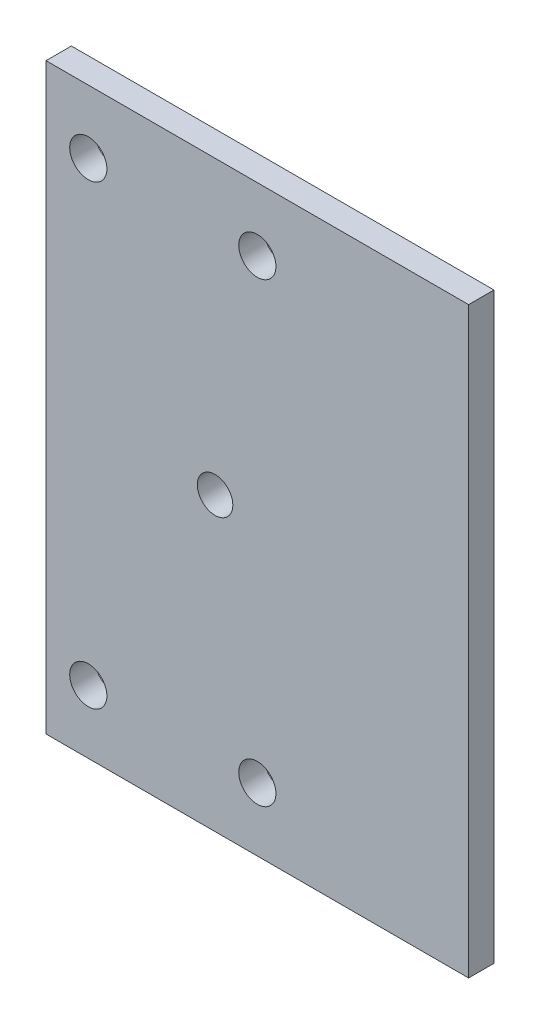
from build123d import *

# Parameters (mm, degrees)
SKETCH_1_W          = 40
SKETCH_1_H          = 29
EXTRUDE_1_DEPTH     = 3
SKETCH_3_W          = 40
SKETCH_3_H          = 3
EXTRUDE_2_DEPTH     = 3
SKETCH_4_W          = 40
SKETCH_4_H          = 3
EXTRUDE_3_DEPTH     = 3
SKETCH_5_W          = 40
SKETCH_5_H          = 3
EXTRUDE_4_DEPTH     = 7
SKETCH_6_W          = 40
SKETCH_6_H          = 3
EXTRUDE_5_DEPTH     = 7
SKETCH_7_W          = 40
SKETCH_7_H          = 3
EXTRUDE_6_DEPTH     = 10
SKETCH_8_W          = 40
SKETCH_8_H          = 3
EXTRUDE_7_DEPTH     = 10
SKETCH_12_W         = 3
SKETCH_12_H         = 69
EXTRUDE_9_DEPTH     = 30
SKETCH_15_R         = 2.1
CUT_EXTRUDE_4_DEPTH = 10
SKETCH_16_W         = 3
SKETCH_16_H         = 69
CUT_EXTRUDE_5_DEPTH = 20
SKETCH_17_R         = 2.2
CUT_EXTRUDE_6_DEPTH = 10


with BuildPart() as part:
    # ｽｹｯﾁ1 → ﾎﾞｽ - 押し出し1 (new body)
    with BuildSketch(Plane.XY):
        Rectangle(SKETCH_1_W, SKETCH_1_H)
    extrude(amount=EXTRUDE_1_DEPTH)

    # ｽｹｯﾁ3 → ﾎﾞｽ - 押し出し2 (add)
    with BuildSketch(Plane(origin=(0, -14.5, 0), x_dir=(-1, 0, 0), z_dir=(0, -1, 0))):
        with Locations((0, -1.5)):
            Rectangle(SKETCH_3_W, SKETCH_3_H)
    extrude(amount=EXTRUDE_2_DEPTH)

    # ｽｹｯﾁ4 → ﾎﾞｽ - 押し出し3 (add)
    with BuildSketch(Plane(origin=(0, 14.5, 0), x_dir=(1, 0, 0), z_dir=(0, 1, 0))):
        with Locations((0, -1.5)):
            Rectangle(SKETCH_4_W, SKETCH_4_H)
    extrude(amount=EXTRUDE_3_DEPTH)

    # ｽｹｯﾁ5 → ﾎﾞｽ - 押し出し4 (add)
    with BuildSketch(Plane.XZ.offset(17.5)):
        with Locations((0, 1.5)):
            Rectangle(SKETCH_5_W, SKETCH_5_H)
    extrude(amount=EXTRUDE_4_DEPTH)

    # ｽｹｯﾁ6 → ﾎﾞｽ - 押し出し5 (add)
    with BuildSketch(Plane(origin=(0, 17.5, 0), x_dir=(1, 0, 0), z_dir=(0, 1, 0))):
        with Locations((0, -1.5)):
            Rectangle(SKETCH_6_W, SKETCH_6_H)
    extrude(amount=EXTRUDE_5_DEPTH)

    # ｽｹｯﾁ7 → ﾎﾞｽ - 押し出し6 (add)
    with BuildSketch(Plane(origin=(0, 24.5, 0), x_dir=(1, 0, 0), z_dir=(0, 1, 0))):
        with Locations((0, -1.5)):
            Rectangle(SKETCH_7_W, SKETCH_7_H)
    extrude(amount=EXTRUDE_6_DEPTH)

    # ｽｹｯﾁ8 → ﾎﾞｽ - 押し出し7 (add)
    with BuildSketch(Plane.XZ.offset(24.5)):
        with Locations((0, 1.5)):
            Rectangle(SKETCH_8_W, SKETCH_8_H)
    extrude(amount=EXTRUDE_7_DEPTH)

    # ｽｹｯﾁ12 → ﾎﾞｽ - 押し出し9 (add)
    with BuildSketch(Plane.ZY.offset(20)):
        with Locations((1.5, 0)):
            Rectangle(SKETCH_12_W, SKETCH_12_H)
    extrude(amount=EXTRUDE_9_DEPTH)

    # ｽｹｯﾁ15 → ｶｯﾄ - 押し出し4 (cut)
    with BuildSketch(Plane.XY.offset(3)):
        with Locations((-10, 0)):
            Circle(SKETCH_15_R)
    extrude(amount=-CUT_EXTRUDE_4_DEPTH, mode=Mode.SUBTRACT)

    # ｽｹｯﾁ16 → ｶｯﾄ - 押し出し5 (cut)
    with BuildSketch(Plane.ZY.offset(50)):
        with Locations((1.5, 0)):
            Rectangle(SKETCH_16_W, SKETCH_16_H)
    extrude(amount=-CUT_EXTRUDE_5_DEPTH, mode=Mode.SUBTRACT)

    # ｽｹｯﾁ17 → ｶｯﾄ - 押し出し6 (cut)
    with BuildSketch(Plane(origin=(0, 0, 0), x_dir=(-1, 0, 0), z_dir=(0, 0, -1))):
        with Locations((5, 27)):
            Circle(SKETCH_17_R)
        with Locations((25, 27)):
            Circle(SKETCH_17_R)
        with Locations((5, -27)):
            Circle(SKETCH_17_R)
        with Locations((25, -27)):
            Circle(SKETCH_17_R)
    extrude(amount=-CUT_EXTRUDE_6_DEPTH, mode=Mode.SUBTRACT)


solid = part.part
